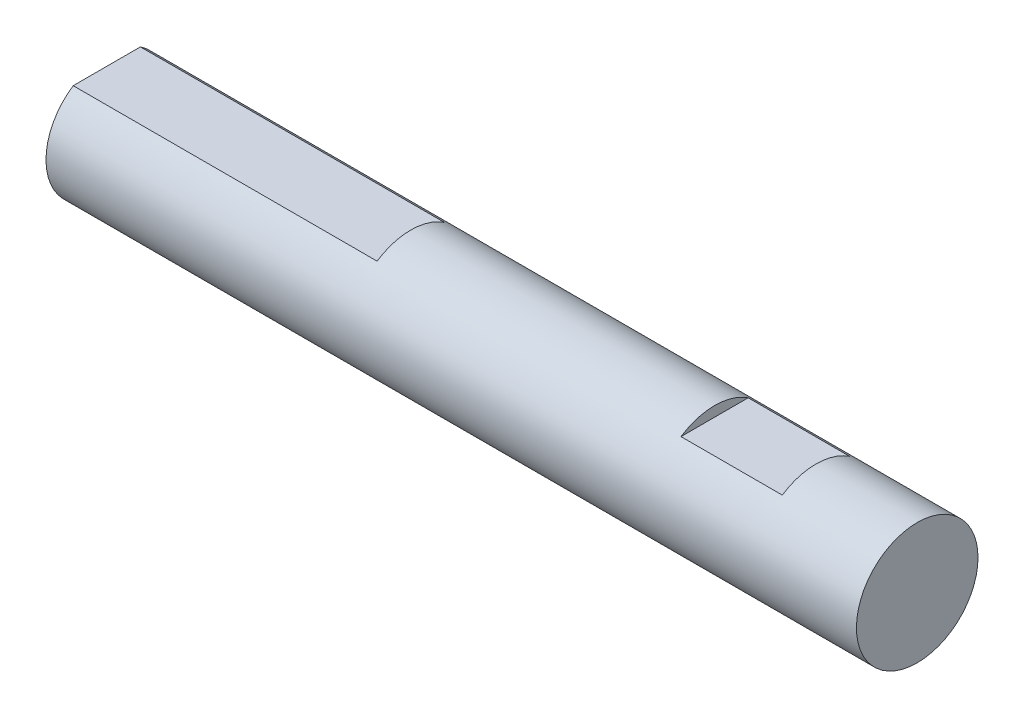
from build123d import *

# Parameters (mm, degrees)
SKETCH_1_R          = 6
EXTRUDE_1_DEPTH     = 70
SKETCH_2_W          = 10
SKETCH_2_H          = 1
SKETCH_2_W_2        = 20
CUT_EXTRUDE_1_DEPTH = 35
EXTRUDE_2_DEPTH     = 10


with BuildPart() as part:
    # 草图1 → 凸台-拉伸1 (new body)
    with BuildSketch(Plane(origin=(0, 0, 0), x_dir=(0, 0, -1), z_dir=(1, 0, 0))):
        Circle(SKETCH_1_R)
    extrude(amount=EXTRUDE_1_DEPTH)

    # 草图2 → 切除-拉伸1 (cut, symmetric)
    with BuildSketch(Plane.XY):
        with Locations((55, 5.5)):
            Rectangle(SKETCH_2_W, SKETCH_2_H)
        with Locations((10, 5.5)):
            Rectangle(SKETCH_2_W_2, SKETCH_2_H)
    extrude(amount=CUT_EXTRUDE_1_DEPTH, both=True, mode=Mode.SUBTRACT)

    # 草图3 → 凸台-拉伸2 (add)
    with BuildSketch(Plane.ZY):
        with BuildLine():
            Line((-3.31662479, 5), (3.31662479, 5))
            ThreePointArc((3.31662479, 5), (0, -6), (-3.31662479, 5))
        make_face()
    extrude(amount=EXTRUDE_2_DEPTH)


solid = part.part
